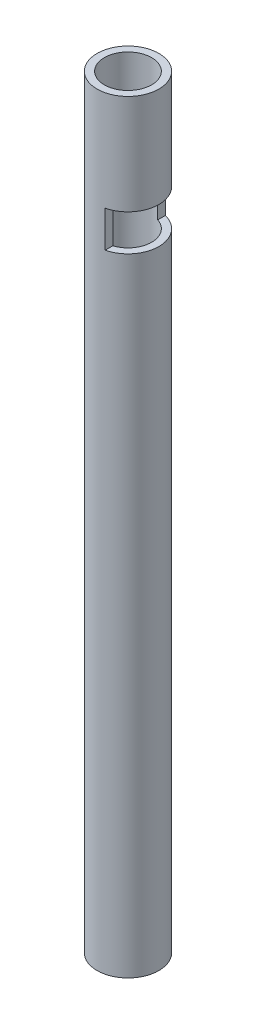
from build123d import *

# Parameters (mm, degrees)
CROQUIS2_R              = 17
CROQUIS2_R_2            = 13
SALIENTE_EXTRUIR1_DEPTH = 420
CROQUIS3_W              = 25
CROQUIS3_H              = 20
CORTAR_EXTRUIR1_DEPTH   = 25


with BuildPart() as part:
    # Croquis2 → Saliente-Extruir1 (new body)
    with BuildSketch(Plane(origin=(0, 0, 0), x_dir=(1, 0, 0), z_dir=(0, 1, 0))):
        Circle(CROQUIS2_R)
        Circle(CROQUIS2_R_2, mode=Mode.SUBTRACT)
    extrude(amount=SALIENTE_EXTRUIR1_DEPTH)

    # Croquis3 → Cortar-Extruir1 (cut, symmetric)
    with BuildSketch(Plane.XY):
        with Locations((16.5, 355)):
            Rectangle(CROQUIS3_W, CROQUIS3_H)
    extrude(amount=CORTAR_EXTRUIR1_DEPTH, both=True, mode=Mode.SUBTRACT)


solid = part.part
